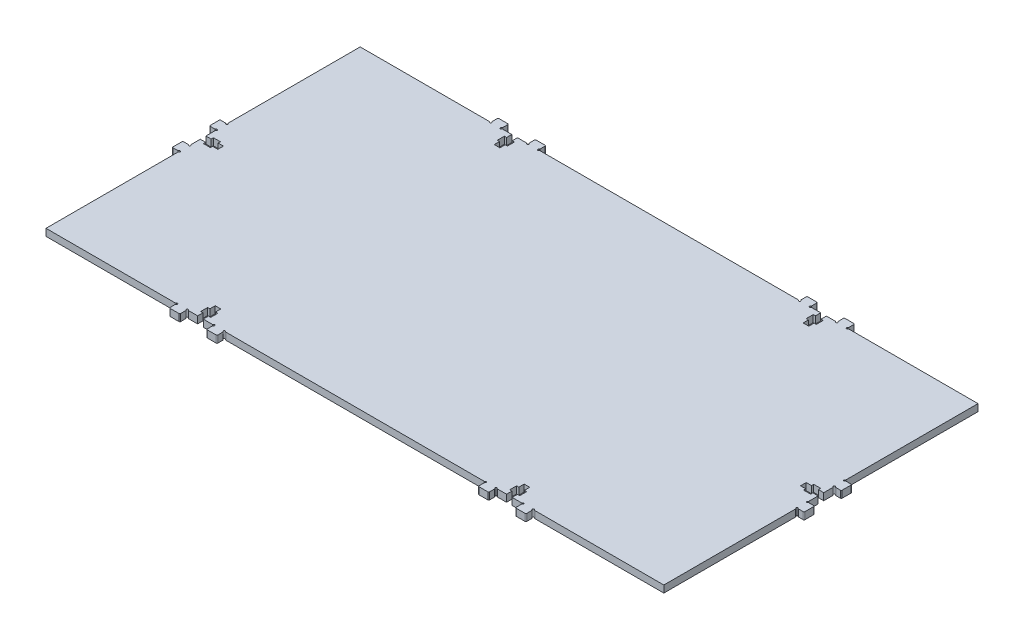
from build123d import *

# Parameters (mm, degrees)
SALIENTE_EXTRUIR1_DEPTH = 4


with BuildPart() as part:
    # Croquis1 → Saliente-Extruir1 (new body)
    with BuildSketch(Plane(origin=(0, 0, 0), x_dir=(1, 0, 0), z_dir=(0, 1, 0))):
        with BuildLine():
            Line((-176.866026001, -13.600040322), (-179.500052001, -13.600040322))
            ThreePointArc((-179.500052001, -13.600040322), (-179.853605391, -13.453593712), (-180.000052001, -13.100040322))
            Line((-180.000052001, -13.100040322), (-180.000052001, -8.100042322))
            ThreePointArc((-180.000052001, -8.100042322), (-179.853605391, -7.746488931), (-179.500052001, -7.600042322))
            Line((-179.500052001, -7.600042322), (-176.866023672, -7.600042322))
            ThreePointArc((-176.866023672, -7.600042322), (-176.616024271, -7.667029274), (-176.433011662, -7.850041125))
            ThreePointArc((-176.433011662, -7.850041125), (-175.6464457, -7.953592758), (-175.749999826, -7.167027125))
            ThreePointArc((-175.749999826, -7.167027125), (-175.933012652, -6.984014409), (-176, -6.734014322))
            Line((-176, -6.734014322), (-176, -1.600020322))
            Line((-176, -1.600020322), (-173.000028001, -1.600020322))
            Line((-173.000028001, -1.600020322), (-173.000028001, -2.875015322))
            Line((-173.000028001, -2.875015322), (-169.000000001, -2.875015322))
            Line((-169.000000001, -2.875015322), (-169.000000001, -1.600020322))
            Line((-169.000000001, -1.600020322), (-166.000000001, -1.600020322))
            Line((-166.000000001, -1.600020322), (-166.000000001, 1.599990678))
            Line((-166.000000001, 1.599990678), (-169.000000001, 1.599990678))
            Line((-169.000000001, 1.599990678), (-169.000000001, 2.874984678))
            Line((-169.000000001, 2.874984678), (-173.000028001, 2.874984678))
            Line((-173.000028001, 2.874984678), (-173.000028001, 1.599990678))
            Line((-173.000028001, 1.599990678), (-176, 1.599990678))
            Line((-176, 1.599990678), (-176, 6.733955299))
            ThreePointArc((-176, 6.733955299), (-175.933012203, 6.983956163), (-175.749998272, 7.166968998))
            ThreePointArc((-175.749998272, 7.166968998), (-175.646443881, 7.953536816), (-176.433011272, 7.849979188))
            ThreePointArc((-176.433011272, 7.849979188), (-176.616024246, 7.666963989), (-176.866026001, 7.599975678))
            Line((-176.866026001, 7.599975678), (-179.500052001, 7.599975678))
            ThreePointArc((-179.500052001, 7.599975678), (-179.853605391, 7.746422288), (-180.000052001, 8.099975678))
            Line((-180.000052001, 8.099975678), (-180.000052001, 13.099973658))
            ThreePointArc((-180.000052001, 13.099973658), (-179.853605391, 13.453527049), (-179.500052001, 13.599973658))
            Line((-179.500052001, 13.599973658), (-176.866023641, 13.599973658))
            ThreePointArc((-176.866023641, 13.599973658), (-176.616024245, 13.532986709), (-176.433011636, 13.349974865))
            ThreePointArc((-176.433011636, 13.349974865), (-175.646445672, 13.24642325), (-175.749999816, 14.032988881))
            ThreePointArc((-175.749999816, 14.032988881), (-175.933012649, 14.216001597), (-176, 14.466001689))
            Line((-176, 14.466001689), (-176, 89.5))
            Line((-176, 89.5), (-102.466031333, 89.5))
            ThreePointArc((-102.466031333, 89.5), (-102.216030529, 89.433012238), (-102.033017703, 89.249998391))
            ThreePointArc((-102.033017703, 89.249998391), (-101.24644999, 89.146444084), (-101.350007375, 89.933011392))
            ThreePointArc((-101.350007375, 89.933011392), (-101.533022427, 90.116024349), (-101.600010678, 90.366026001))
            Line((-101.600010678, 90.366026001), (-101.600010678, 93.170052001))
            ThreePointArc((-101.600010678, 93.170052001), (-101.453564069, 93.523605391), (-101.100010678, 93.670052001))
            Line((-101.100010678, 93.670052001), (-96.100012678, 93.670052001))
            ThreePointArc((-96.100012678, 93.670052001), (-95.746459288, 93.523605391), (-95.600012678, 93.170052001))
            Line((-95.600012678, 93.170052001), (-95.600012678, 90.366023672))
            ThreePointArc((-95.600012678, 90.366023672), (-95.666999631, 90.116024271), (-95.850011481, 89.933011662))
            ThreePointArc((-95.850011481, 89.933011662), (-95.953563114, 89.1464457), (-95.166997481, 89.249999826))
            ThreePointArc((-95.166997481, 89.249999826), (-94.983984766, 89.433012652), (-94.733984679, 89.5))
            Line((-94.733984679, 89.5), (-89.599990678, 89.5))
            Line((-89.599990678, 89.5), (-89.599990678, 86.500028001))
            Line((-89.599990678, 86.500028001), (-90.874985678, 86.500028001))
            Line((-90.874985678, 86.500028001), (-90.874985678, 82.500000001))
            Line((-90.874985678, 82.500000001), (-89.599990678, 82.500000001))
            Line((-89.599990678, 82.500000001), (-89.599990678, 79.500000001))
            Line((-89.599990678, 79.500000001), (-86.399979678, 79.500000001))
            Line((-86.399979678, 79.500000001), (-86.399979678, 82.500000001))
            Line((-86.399979678, 82.500000001), (-85.124985678, 82.500000001))
            Line((-85.124985678, 82.500000001), (-85.124985678, 86.500028001))
            Line((-85.124985678, 86.500028001), (-86.399979678, 86.500028001))
            Line((-86.399979678, 86.500028001), (-86.399979678, 89.5))
            Line((-86.399979678, 89.5), (-81.266015057, 89.5))
            ThreePointArc((-81.266015057, 89.5), (-81.016014193, 89.433012203), (-80.833001358, 89.249998272))
            ThreePointArc((-80.833001358, 89.249998272), (-80.04643354, 89.146443881), (-80.149991168, 89.933011272))
            ThreePointArc((-80.149991168, 89.933011272), (-80.333006367, 90.116024246), (-80.399994678, 90.366026001))
            Line((-80.399994678, 90.366026001), (-80.399994678, 93.170052001))
            ThreePointArc((-80.399994678, 93.170052001), (-80.253548069, 93.523605391), (-79.899994678, 93.670052001))
            Line((-79.899994678, 93.670052001), (-74.899996698, 93.670052001))
            ThreePointArc((-74.899996698, 93.670052001), (-74.546443307, 93.523605391), (-74.399996698, 93.170052001))
            Line((-74.399996698, 93.170052001), (-74.399996698, 90.366023641))
            ThreePointArc((-74.399996698, 90.366023641), (-74.466983648, 90.116024245), (-74.649995491, 89.933011636))
            ThreePointArc((-74.649995491, 89.933011636), (-74.753547106, 89.146445672), (-73.966981475, 89.249999816))
            ThreePointArc((-73.966981475, 89.249999816), (-73.783968759, 89.433012649), (-73.533968667, 89.5))
            Line((-73.533968667, 89.5), (73.533968667, 89.5))
            ThreePointArc((73.533968667, 89.5), (73.783969471, 89.433012238), (73.966982297, 89.249998391))
            ThreePointArc((73.966982297, 89.249998391), (74.75355001, 89.146444084), (74.649992625, 89.933011392))
            ThreePointArc((74.649992625, 89.933011392), (74.466977573, 90.116024349), (74.399989322, 90.366026001))
            Line((74.399989322, 90.366026001), (74.399989322, 93.170052001))
            ThreePointArc((74.399989322, 93.170052001), (74.546435931, 93.523605391), (74.899989322, 93.670052001))
            Line((74.899989322, 93.670052001), (79.899987322, 93.670052001))
            ThreePointArc((79.899987322, 93.670052001), (80.253540712, 93.523605391), (80.399987322, 93.170052001))
            Line((80.399987322, 93.170052001), (80.399987322, 90.366023672))
            ThreePointArc((80.399987322, 90.366023672), (80.333000369, 90.116024271), (80.149988519, 89.933011662))
            ThreePointArc((80.149988519, 89.933011662), (80.046436886, 89.1464457), (80.833002519, 89.249999826))
            ThreePointArc((80.833002519, 89.249999826), (81.016015234, 89.433012652), (81.266015321, 89.5))
            Line((81.266015321, 89.5), (86.400009322, 89.5))
            Line((86.400009322, 89.5), (86.400009322, 86.500028001))
            Line((86.400009322, 86.500028001), (85.125014322, 86.500028001))
            Line((85.125014322, 86.500028001), (85.125014322, 82.500000001))
            Line((85.125014322, 82.500000001), (86.400009322, 82.500000001))
            Line((86.400009322, 82.500000001), (86.400009322, 79.500000001))
            Line((86.400009322, 79.500000001), (89.600020322, 79.500000001))
            Line((89.600020322, 79.500000001), (89.600020322, 82.500000001))
            Line((89.600020322, 82.500000001), (90.875014322, 82.500000001))
            Line((90.875014322, 82.500000001), (90.875014322, 86.500028001))
            Line((90.875014322, 86.500028001), (89.600020322, 86.500028001))
            Line((89.600020322, 86.500028001), (89.600020322, 89.5))
            Line((89.600020322, 89.5), (94.733984943, 89.5))
            ThreePointArc((94.733984943, 89.5), (94.983985807, 89.433012203), (95.166998642, 89.249998272))
            ThreePointArc((95.166998642, 89.249998272), (95.95356646, 89.146443881), (95.850008832, 89.933011272))
            ThreePointArc((95.850008832, 89.933011272), (95.666993633, 90.116024246), (95.600005322, 90.366026001))
            Line((95.600005322, 90.366026001), (95.600005322, 93.170052001))
            ThreePointArc((95.600005322, 93.170052001), (95.746451931, 93.523605391), (96.100005322, 93.670052001))
            Line((96.100005322, 93.670052001), (101.100003302, 93.670052001))
            ThreePointArc((101.100003302, 93.670052001), (101.453556693, 93.523605391), (101.600003302, 93.170052001))
            Line((101.600003302, 93.170052001), (101.600003302, 90.366023641))
            ThreePointArc((101.600003302, 90.366023641), (101.533016352, 90.116024245), (101.350004509, 89.933011636))
            ThreePointArc((101.350004509, 89.933011636), (101.246452894, 89.146445672), (102.033018525, 89.249999816))
            ThreePointArc((102.033018525, 89.249999816), (102.216031241, 89.433012649), (102.466031333, 89.5))
            Line((102.466031333, 89.5), (176, 89.5))
            Line((176, 89.5), (176, 14.466001689))
            ThreePointArc((176, 14.466001689), (175.933012649, 14.216001597), (175.749999816, 14.032988881))
            ThreePointArc((175.749999816, 14.032988881), (175.646445672, 13.24642325), (176.433011636, 13.349974865))
            ThreePointArc((176.433011636, 13.349974865), (176.616024245, 13.532986709), (176.866023641, 13.599973658))
            Line((176.866023641, 13.599973658), (179.500052001, 13.599973658))
            ThreePointArc((179.500052001, 13.599973658), (179.853605391, 13.453527049), (180.000052001, 13.099973658))
            Line((180.000052001, 13.099973658), (180.000052001, 8.099975678))
            ThreePointArc((180.000052001, 8.099975678), (179.853605391, 7.746422288), (179.500052001, 7.599975678))
            Line((179.500052001, 7.599975678), (176.866026001, 7.599975678))
            ThreePointArc((176.866026001, 7.599975678), (176.616024246, 7.666963989), (176.433011272, 7.849979188))
            ThreePointArc((176.433011272, 7.849979188), (175.646443881, 7.953536816), (175.749998272, 7.166968998))
            ThreePointArc((175.749998272, 7.166968998), (175.933012203, 6.983956163), (176, 6.733955299))
            Line((176, 6.733955299), (176, 1.599990678))
            Line((176, 1.599990678), (173.000028001, 1.599990678))
            Line((173.000028001, 1.599990678), (173.000028001, 2.874984678))
            Line((173.000028001, 2.874984678), (169.000000001, 2.874984678))
            Line((169.000000001, 2.874984678), (169.000000001, 1.599990678))
            Line((169.000000001, 1.599990678), (166.000000001, 1.599990678))
            Line((166.000000001, 1.599990678), (166.000000001, -1.600020322))
            Line((166.000000001, -1.600020322), (169.000000001, -1.600020322))
            Line((169.000000001, -1.600020322), (169.000000001, -2.875015322))
            Line((169.000000001, -2.875015322), (173.000028001, -2.875015322))
            Line((173.000028001, -2.875015322), (173.000028001, -1.600020322))
            Line((173.000028001, -1.600020322), (176, -1.600020322))
            Line((176, -1.600020322), (176, -6.734014322))
            ThreePointArc((176, -6.734014322), (175.933012652, -6.984014409), (175.749999826, -7.167027125))
            ThreePointArc((175.749999826, -7.167027125), (175.6464457, -7.953592758), (176.433011662, -7.850041125))
            ThreePointArc((176.433011662, -7.850041125), (176.616024271, -7.667029274), (176.866023672, -7.600042322))
            Line((176.866023672, -7.600042322), (179.500052001, -7.600042322))
            ThreePointArc((179.500052001, -7.600042322), (179.853605391, -7.746488931), (180.000052001, -8.100042322))
            Line((180.000052001, -8.100042322), (180.000052001, -13.100040322))
            ThreePointArc((180.000052001, -13.100040322), (179.853605391, -13.453593712), (179.500052001, -13.600040322))
            Line((179.500052001, -13.600040322), (176.866026001, -13.600040322))
            ThreePointArc((176.866026001, -13.600040322), (176.616024349, -13.53305207), (176.433011392, -13.350037019))
            ThreePointArc((176.433011392, -13.350037019), (175.646444084, -13.246479633), (175.749998391, -14.033047346))
            ThreePointArc((175.749998391, -14.033047346), (175.933012238, -14.216060172), (176, -14.466060977))
            Line((176, -14.466060977), (176, -89.5))
            Line((176, -89.5), (102.466031333, -89.5))
            ThreePointArc((102.466031333, -89.5), (102.216031241, -89.433012649), (102.033018525, -89.249999816))
            ThreePointArc((102.033018525, -89.249999816), (101.246452894, -89.146445672), (101.350004509, -89.933011636))
            ThreePointArc((101.350004509, -89.933011636), (101.533016352, -90.116024245), (101.600003302, -90.366023641))
            Line((101.600003302, -90.366023641), (101.600003302, -93.170052001))
            ThreePointArc((101.600003302, -93.170052001), (101.453556693, -93.523605391), (101.100003302, -93.670052001))
            Line((101.100003302, -93.670052001), (96.100005322, -93.670052001))
            ThreePointArc((96.100005322, -93.670052001), (95.746451931, -93.523605391), (95.600005322, -93.170052001))
            Line((95.600005322, -93.170052001), (95.600005322, -90.366026001))
            ThreePointArc((95.600005322, -90.366026001), (95.666993633, -90.116024246), (95.850008832, -89.933011272))
            ThreePointArc((95.850008832, -89.933011272), (95.95356646, -89.146443881), (95.166998642, -89.249998272))
            ThreePointArc((95.166998642, -89.249998272), (94.983985807, -89.433012203), (94.733984943, -89.5))
            Line((94.733984943, -89.5), (89.600020322, -89.5))
            Line((89.600020322, -89.5), (89.600020322, -86.500028001))
            Line((89.600020322, -86.500028001), (90.875014322, -86.500028001))
            Line((90.875014322, -86.500028001), (90.875014322, -82.500000001))
            Line((90.875014322, -82.500000001), (89.600020322, -82.500000001))
            Line((89.600020322, -82.500000001), (89.600020322, -79.500000001))
            Line((89.600020322, -79.500000001), (86.400009322, -79.500000001))
            Line((86.400009322, -79.500000001), (86.400009322, -82.500000001))
            Line((86.400009322, -82.500000001), (85.125014322, -82.500000001))
            Line((85.125014322, -82.500000001), (85.125014322, -86.500028001))
            Line((85.125014322, -86.500028001), (86.400009322, -86.500028001))
            Line((86.400009322, -86.500028001), (86.400009322, -89.5))
            Line((86.400009322, -89.5), (81.266015321, -89.5))
            ThreePointArc((81.266015321, -89.5), (81.016015234, -89.433012652), (80.833002519, -89.249999826))
            ThreePointArc((80.833002519, -89.249999826), (80.046436886, -89.1464457), (80.149988519, -89.933011662))
            ThreePointArc((80.149988519, -89.933011662), (80.333000369, -90.116024271), (80.399987322, -90.366023672))
            Line((80.399987322, -90.366023672), (80.399987322, -93.170052001))
            ThreePointArc((80.399987322, -93.170052001), (80.253540712, -93.523605391), (79.899987322, -93.670052001))
            Line((79.899987322, -93.670052001), (74.899989322, -93.670052001))
            ThreePointArc((74.899989322, -93.670052001), (74.546435931, -93.523605391), (74.399989322, -93.170052001))
            Line((74.399989322, -93.170052001), (74.399989322, -90.366026001))
            ThreePointArc((74.399989322, -90.366026001), (74.466977573, -90.116024349), (74.649992625, -89.933011392))
            ThreePointArc((74.649992625, -89.933011392), (74.75355001, -89.146444084), (73.966982297, -89.249998391))
            ThreePointArc((73.966982297, -89.249998391), (73.783969471, -89.433012238), (73.533968667, -89.5))
            Line((73.533968667, -89.5), (-73.533968667, -89.5))
            ThreePointArc((-73.533968667, -89.5), (-73.783968759, -89.433012649), (-73.966981475, -89.249999816))
            ThreePointArc((-73.966981475, -89.249999816), (-74.753547106, -89.146445672), (-74.649995491, -89.933011636))
            ThreePointArc((-74.649995491, -89.933011636), (-74.466983648, -90.116024245), (-74.399996698, -90.366023641))
            Line((-74.399996698, -90.366023641), (-74.399996698, -93.170052001))
            ThreePointArc((-74.399996698, -93.170052001), (-74.546443307, -93.523605391), (-74.899996698, -93.670052001))
            Line((-74.899996698, -93.670052001), (-79.899994678, -93.670052001))
            ThreePointArc((-79.899994678, -93.670052001), (-80.253548069, -93.523605391), (-80.399994678, -93.170052001))
            Line((-80.399994678, -93.170052001), (-80.399994678, -90.366026001))
            ThreePointArc((-80.399994678, -90.366026001), (-80.333006367, -90.116024246), (-80.149991168, -89.933011272))
            ThreePointArc((-80.149991168, -89.933011272), (-80.04643354, -89.146443881), (-80.833001358, -89.249998272))
            ThreePointArc((-80.833001358, -89.249998272), (-81.016014193, -89.433012203), (-81.266015057, -89.5))
            Line((-81.266015057, -89.5), (-86.399979678, -89.5))
            Line((-86.399979678, -89.5), (-86.399979678, -86.500028001))
            Line((-86.399979678, -86.500028001), (-85.124985678, -86.500028001))
            Line((-85.124985678, -86.500028001), (-85.124985678, -82.500000001))
            Line((-85.124985678, -82.500000001), (-86.399979678, -82.500000001))
            Line((-86.399979678, -82.500000001), (-86.399979678, -79.500000001))
            Line((-86.399979678, -79.500000001), (-89.599990678, -79.500000001))
            Line((-89.599990678, -79.500000001), (-89.599990678, -82.500000001))
            Line((-89.599990678, -82.500000001), (-90.874985678, -82.500000001))
            Line((-90.874985678, -82.500000001), (-90.874985678, -86.500028001))
            Line((-90.874985678, -86.500028001), (-89.599990678, -86.500028001))
            Line((-89.599990678, -86.500028001), (-89.599990678, -89.5))
            Line((-89.599990678, -89.5), (-94.733984679, -89.5))
            ThreePointArc((-94.733984679, -89.5), (-94.983984766, -89.433012652), (-95.166997481, -89.249999826))
            ThreePointArc((-95.166997481, -89.249999826), (-95.953563114, -89.1464457), (-95.850011481, -89.933011662))
            ThreePointArc((-95.850011481, -89.933011662), (-95.666999631, -90.116024271), (-95.600012678, -90.366023672))
            Line((-95.600012678, -90.366023672), (-95.600012678, -93.170052001))
            ThreePointArc((-95.600012678, -93.170052001), (-95.746459288, -93.523605391), (-96.100012678, -93.670052001))
            Line((-96.100012678, -93.670052001), (-101.100010678, -93.670052001))
            ThreePointArc((-101.100010678, -93.670052001), (-101.453564069, -93.523605391), (-101.600010678, -93.170052001))
            Line((-101.600010678, -93.170052001), (-101.600010678, -90.366026001))
            ThreePointArc((-101.600010678, -90.366026001), (-101.533022427, -90.116024349), (-101.350007375, -89.933011392))
            ThreePointArc((-101.350007375, -89.933011392), (-101.24644999, -89.146444084), (-102.033017703, -89.249998391))
            ThreePointArc((-102.033017703, -89.249998391), (-102.216030529, -89.433012238), (-102.466031333, -89.5))
            Line((-102.466031333, -89.5), (-176, -89.5))
            Line((-176, -89.5), (-176, -14.466060977))
            ThreePointArc((-176, -14.466060977), (-175.933012238, -14.216060172), (-175.749998391, -14.033047346))
            ThreePointArc((-175.749998391, -14.033047346), (-175.646444084, -13.246479633), (-176.433011392, -13.350037019))
            ThreePointArc((-176.433011392, -13.350037019), (-176.616024349, -13.53305207), (-176.866026001, -13.600040322))
        make_face()
    extrude(amount=SALIENTE_EXTRUIR1_DEPTH)


solid = part.part
